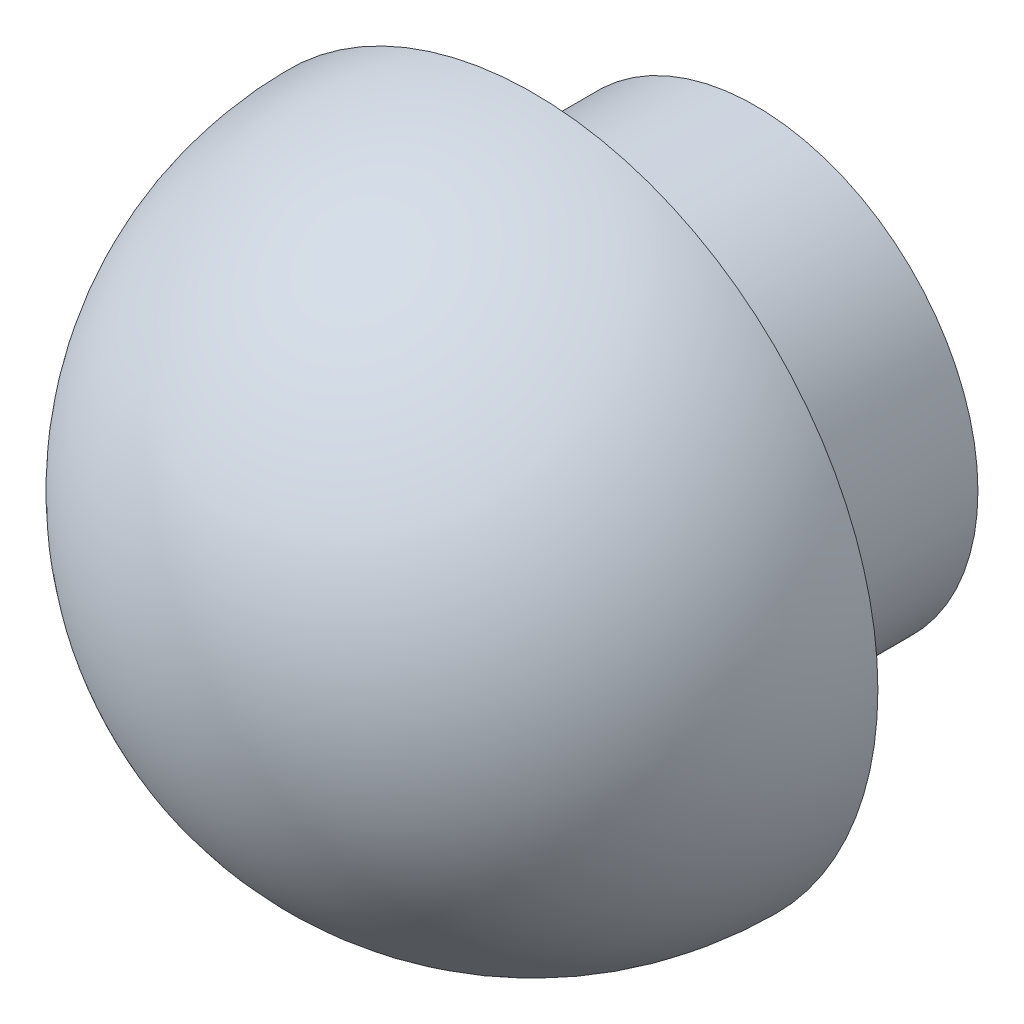
from build123d import *

# Parameters (mm, degrees)
SKETCH1_R           = 15
BOSS_EXTRUDE1_DEPTH = 15
REVOLVE1_ANGLE      = 180


with BuildPart() as part:
    # Sketch1 → Boss-Extrude1 (new body)
    with BuildSketch(Plane.XY):
        Circle(SKETCH1_R)
    extrude(amount=BOSS_EXTRUDE1_DEPTH)

    # Sketch2 → Revolve1 (revolve)
    with BuildSketch(Plane.XY.offset(15)):
        with BuildLine():
            Line((0, 23.25), (0, -23.25))
            ThreePointArc((0, -23.25), (23.25, 0), (0, 23.25))
        make_face()
    revolve(axis=Axis((0, 0, 15), (0, -1, 0)), revolution_arc=REVOLVE1_ANGLE)


solid = part.part
